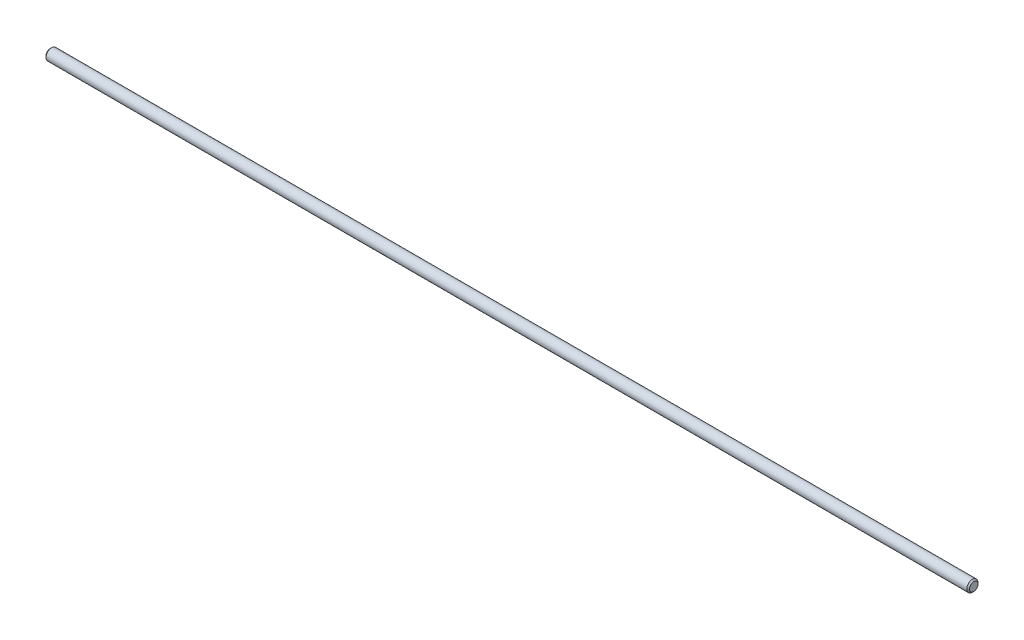
from build123d import *

# Parameters (mm, degrees)
SKETCH2_R                = 1
BOSS_EXTRUDE1_DEPTH      = 82.175
BOSS_EXTRUDE1_DEPTH_BACK = 82.175
SKETCH5_OUTSIDE_W        = 367.574
SKETCH5_OUTSIDE_H        = 367.574
SKETCH5_OUTSIDE_R        = 0.75256417
CUT_EXTRUDE1_DEPTH       = 165.35
CUT_EXTRUDE1_TAPER       = 45


with BuildPart() as part:
    # Sketch2 → Boss-Extrude1 (new body, two sides)
    with BuildSketch(Plane(origin=(0, 0, 0), x_dir=(0, 0, -1), z_dir=(1, 0, 0))) as boss_extrude1_sk:
        Circle(SKETCH2_R)
    extrude(amount=BOSS_EXTRUDE1_DEPTH)
    extrude(boss_extrude1_sk.sketch, amount=-BOSS_EXTRUDE1_DEPTH_BACK)

    # Sketch5 outside → Cut-Extrude1 (cut, through all)
    with BuildSketch(Plane(origin=(82.175, 0, 0), x_dir=(0, 0, -1), z_dir=(1, 0, 0))):
        Rectangle(SKETCH5_OUTSIDE_W, SKETCH5_OUTSIDE_H)
        Circle(SKETCH5_OUTSIDE_R, mode=Mode.SUBTRACT)
    cut_extrude1 = extrude(amount=-CUT_EXTRUDE1_DEPTH, taper=CUT_EXTRUDE1_TAPER, mode=Mode.SUBTRACT)

    # Mirror1: Cut-Extrude1 across plane
    add(cut_extrude1.mirror(Plane(origin=(0, 0, 0), x_dir=(0, 0, 1), z_dir=(1, 0, 0))), mode=Mode.SUBTRACT)


solid = part.part
